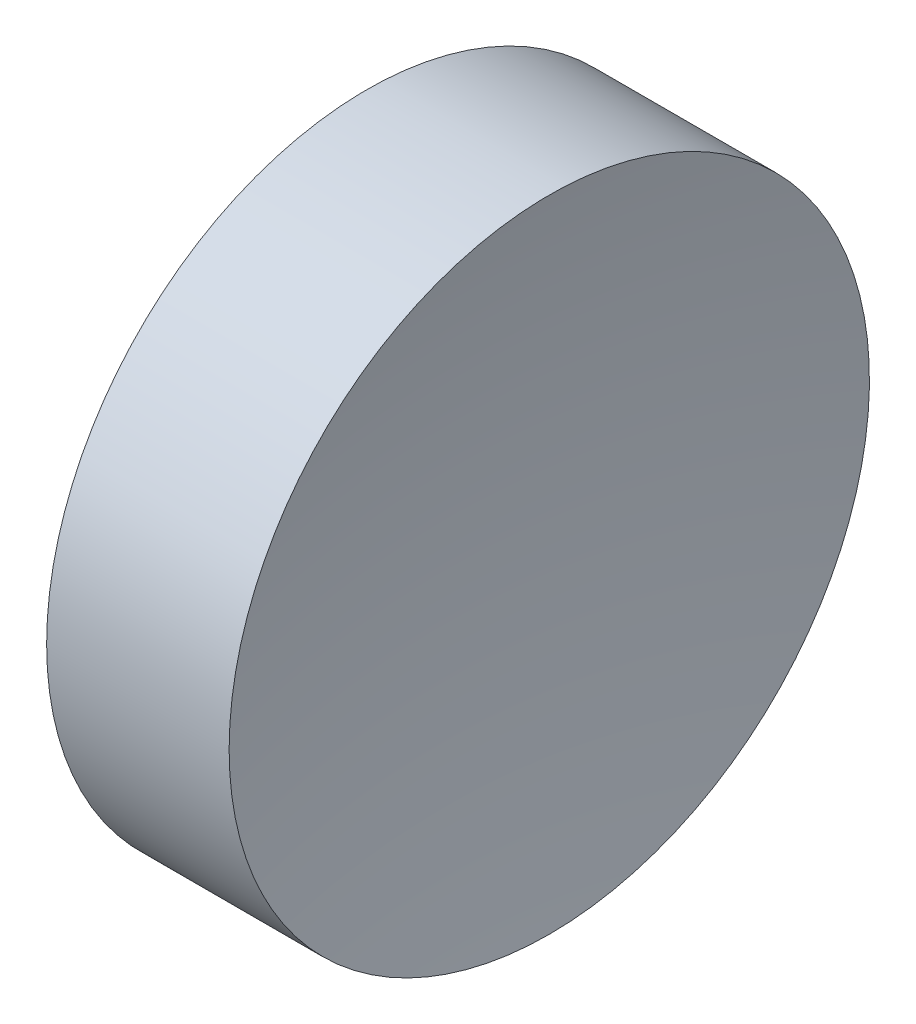
from build123d import *


with BuildPart() as part:
    # 草图1 → 旋转1 (revolve)
    with BuildSketch(Plane.XY, mode=Mode.PRIVATE) as revolve_1_sk:
        with BuildLine():
            Line((115.092655535, 69.378021123), (115.092655535, 81.878021123))
            Line((115.092655535, 81.878021123), (122.217768961, 81.878021123))
            ThreePointArc((122.217768961, 81.878021123), (121.374501296, 75.653287656), (121.092655531, 69.378021123))
            Line((121.092655531, 69.378021123), (115.092655535, 69.378021123))
        make_face()
    revolve(revolve_1_sk.sketch.rotate(Axis((108.985143002, 69.378021123, 0), (1, 0, 0)), 180), axis=Axis((108.985143002, 69.378021123, 0), (1, 0, 0)))  # turned: the seam where the file's is


solid = part.part
